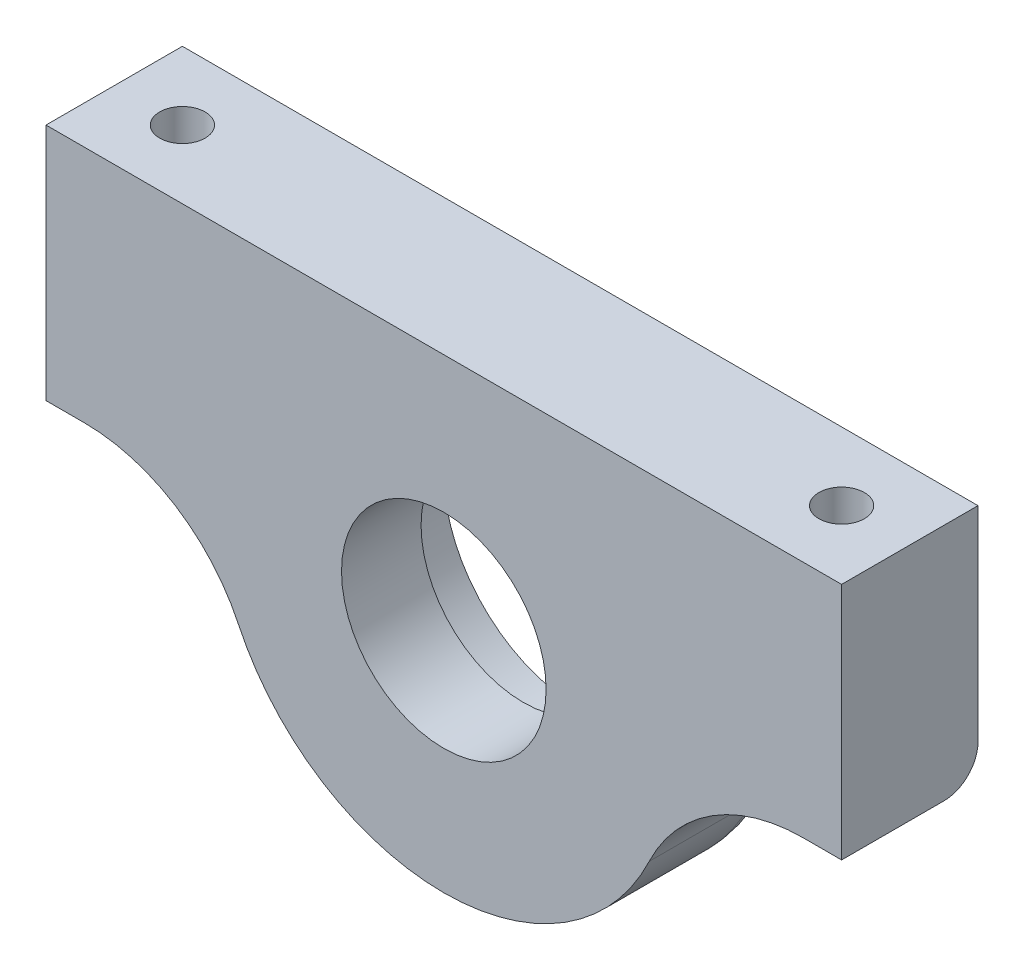
from build123d import *

# Parameters (mm, degrees)
SKETCH1_R           = 9
BOSS_EXTRUDE1_DEPTH = 6
SKETCH2_R           = 12
CUT_EXTRUDE1_DEPTH  = 5
SKETCH3_R           = 2
CUT_EXTRUDE2_DEPTH  = 10
FILLET1_R           = 3


with BuildPart() as part:
    # Sketch1 → Boss-Extrude1 (new body, symmetric)
    with BuildSketch(Plane.XY):
        with BuildLine():
            Line((-35, 21), (35, 21))
            Line((35, 21), (35, 0))
            Line((35, 0), (31.622776602, 0))
            ThreePointArc((31.622776602, 0), (23.604939344, -2.322686179), (18.070158058, -8.571428571))
            ThreePointArc((18.070158058, -8.571428571), (0, -20), (-18.070158058, -8.571428571))
            ThreePointArc((-18.070158058, -8.571428571), (-23.604939344, -2.322686179), (-31.622776602, 0))
            Line((-31.622776602, 0), (-35, 0))
            Line((-35, 0), (-35, 21))
        make_face()
        Circle(SKETCH1_R, mode=Mode.SUBTRACT)
    extrude(amount=BOSS_EXTRUDE1_DEPTH, both=True)

    # Sketch2 → Cut-Extrude1 (cut)
    with BuildSketch(Plane(origin=(0, 0, -6), x_dir=(-1, 0, 0), z_dir=(0, 0, -1))):
        Circle(SKETCH2_R)
    extrude(amount=-CUT_EXTRUDE1_DEPTH, mode=Mode.SUBTRACT)

    # Sketch3 → Cut-Extrude2 (cut)
    with BuildSketch(Plane(origin=(0, 21, 0), x_dir=(1, 0, 0), z_dir=(0, 1, 0))):
        with Locations((-29, 0)):
            Circle(SKETCH3_R)
        with Locations((29, 0)):
            Circle(SKETCH3_R)
    extrude(amount=-CUT_EXTRUDE2_DEPTH, mode=Mode.SUBTRACT)

    # Fillet1
    fillet1_edges = [part.edges().sort_by_distance(p)[0] for p in [
        (0, -20, -6),
        (-23.604939344, -2.322686179, -6),
        (-33.311388301, 0, -6),
        (33.311388301, 0, -6),
        (23.604939344, -2.322686179, -6),
    ]]
    fillet(fillet1_edges, radius=FILLET1_R)


solid = part.part
